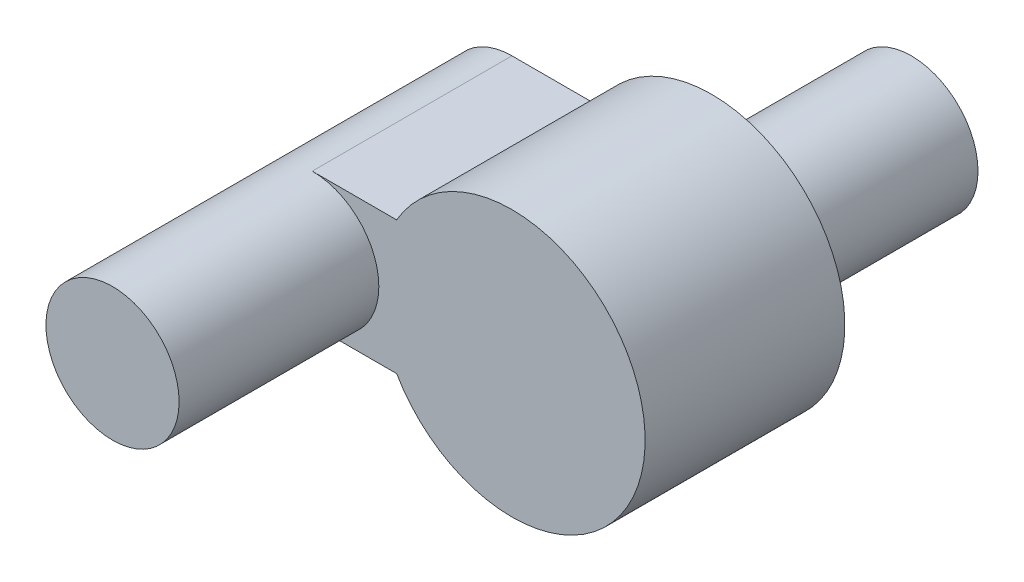
from build123d import *

# Parameters (mm, degrees)
BOSS_EXTRUDE1_DEPTH = 3
SKETCH2_R           = 1
BOSS_EXTRUDE2_DEPTH = 3
SKETCH3_R           = 1
BOSS_EXTRUDE3_DEPTH = 3


with BuildPart() as part:
    # Sketch1 → Boss-Extrude1 (new body)
    with BuildSketch(Plane.XY):
        with BuildLine():
            Line((-10.074027202, 4.819774295), (-8.80607801, 4.819774295))
            ThreePointArc((-8.80607801, 4.819774295), (-5.074027202, 3.819774295), (-8.80607801, 2.819774295))
            Line((-8.80607801, 2.819774295), (-10.074027202, 2.819774295))
            ThreePointArc((-10.074027202, 2.819774295), (-11.074027202, 3.819774295), (-10.074027202, 4.819774295))
        make_face()
    extrude(amount=BOSS_EXTRUDE1_DEPTH)

    # Sketch2 → Boss-Extrude2 (add)
    with BuildSketch(Plane.XY.offset(3)):
        with Locations((-10.074027202, 3.819774295)):
            Circle(SKETCH2_R)
    extrude(amount=BOSS_EXTRUDE2_DEPTH)

    # Sketch3 → Boss-Extrude3 (add)
    with BuildSketch(Plane(origin=(0, 0, 0), x_dir=(-1, 0, 0), z_dir=(0, 0, -1))):
        with Locations((7.074027202, 3.819774295)):
            Circle(SKETCH3_R)
    extrude(amount=BOSS_EXTRUDE3_DEPTH)


solid = part.part
